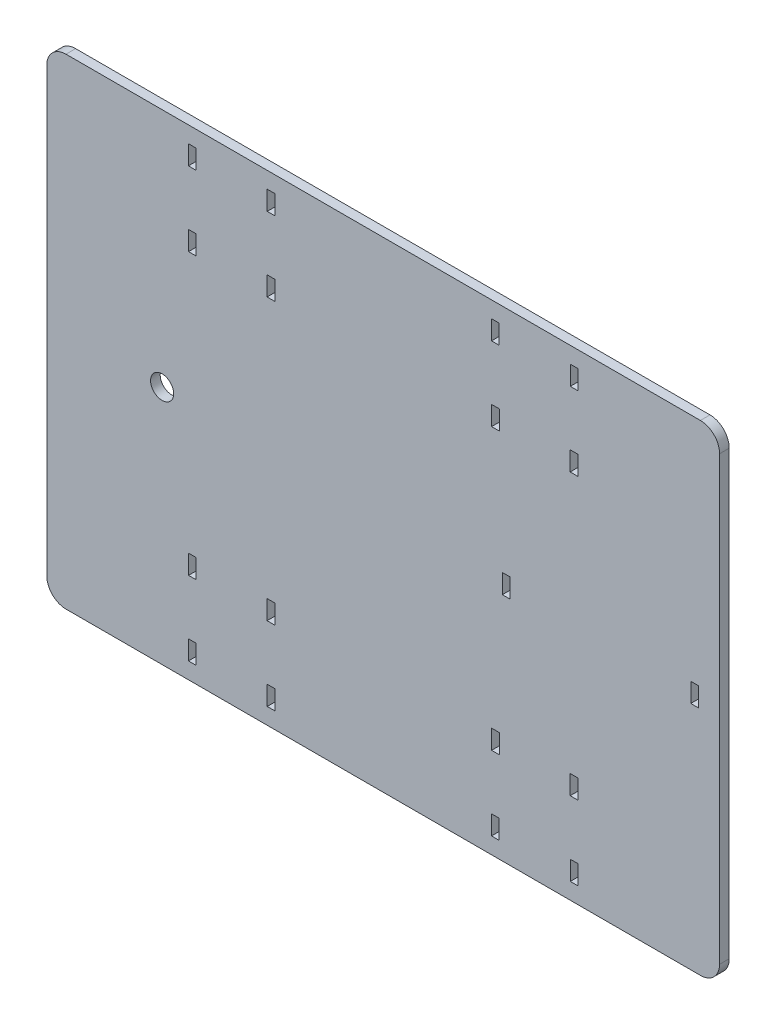
from build123d import *

# Parameters (mm, degrees)
BOSS_EXTRUDE1_DEPTH = 5
SKETCH2_W           = 4
SKETCH2_H           = 10
CUT_EXTRUDE1_DEPTH  = 10
SKETCH3_R           = 6
SKETCH3_W           = 4
SKETCH3_H           = 10
CUT_EXTRUDE2_DEPTH  = 10


with BuildPart() as part:
    # Sketch1 → Boss-Extrude1 (new body)
    with BuildSketch(Plane.XY):
        with BuildLine():
            Line((-165, 125), (165, 125))
            ThreePointArc((165, 125), (172.071067812, 122.071067812), (175, 115))
            Line((175, 115), (175, -115))
            ThreePointArc((175, -115), (172.071067812, -122.071067812), (165, -125))
            Line((165, -125), (-165, -125))
            ThreePointArc((-165, -125), (-172.071067812, -122.071067812), (-175, -115))
            Line((-175, -115), (-175, 115))
            ThreePointArc((-175, 115), (-172.071067812, 122.071067812), (-165, 125))
        make_face()
    extrude(amount=BOSS_EXTRUDE1_DEPTH)

    # Sketch2 → Cut-Extrude1 (cut)
    with BuildSketch(Plane.XY.offset(5)):
        with Locations((99.328502067, 111.512009489)):
            Rectangle(SKETCH2_W, SKETCH2_H)
        with Locations((99.262510454, 72.917517572)):
            Rectangle(SKETCH2_W, SKETCH2_H)
        with Locations((58.394493679, 72.917517572)):
            Rectangle(SKETCH2_W, SKETCH2_H)
        with Locations((58.328502067, 111.512009489)):
            Rectangle(SKETCH2_W, SKETCH2_H)
        with Locations((58.328502067, -111.512009489)):
            Rectangle(SKETCH2_W, SKETCH2_H)
        with Locations((58.394493679, -72.917517572)):
            Rectangle(SKETCH2_W, SKETCH2_H)
        with Locations((99.262510454, -72.917517572)):
            Rectangle(SKETCH2_W, SKETCH2_H)
        with Locations((99.328502067, -111.512009489)):
            Rectangle(SKETCH2_W, SKETCH2_H)
        with Locations((-99.328502067, -111.512009489)):
            Rectangle(SKETCH2_W, SKETCH2_H)
        with Locations((-99.262510454, -72.917517572)):
            Rectangle(SKETCH2_W, SKETCH2_H)
        with Locations((-58.394493679, -72.917517572)):
            Rectangle(SKETCH2_W, SKETCH2_H)
        with Locations((-58.328502067, -111.512009489)):
            Rectangle(SKETCH2_W, SKETCH2_H)
        with Locations((-58.328502067, 111.512009489)):
            Rectangle(SKETCH2_W, SKETCH2_H)
        with Locations((-58.394493679, 72.917517572)):
            Rectangle(SKETCH2_W, SKETCH2_H)
        with Locations((-99.262510454, 72.917517572)):
            Rectangle(SKETCH2_W, SKETCH2_H)
        with Locations((-99.328502067, 111.512009489)):
            Rectangle(SKETCH2_W, SKETCH2_H)
    extrude(amount=-CUT_EXTRUDE1_DEPTH, mode=Mode.SUBTRACT)

    # Sketch3 → Cut-Extrude2 (cut)
    with BuildSketch(Plane.XY.offset(5)):
        with Locations((-115, 0)):
            Circle(SKETCH3_R)
        with Locations((162, 0)):
            Rectangle(SKETCH3_W, SKETCH3_H)
        with Locations((64, 0)):
            Rectangle(SKETCH3_W, SKETCH3_H)
    extrude(amount=-CUT_EXTRUDE2_DEPTH, mode=Mode.SUBTRACT)


solid = part.part
